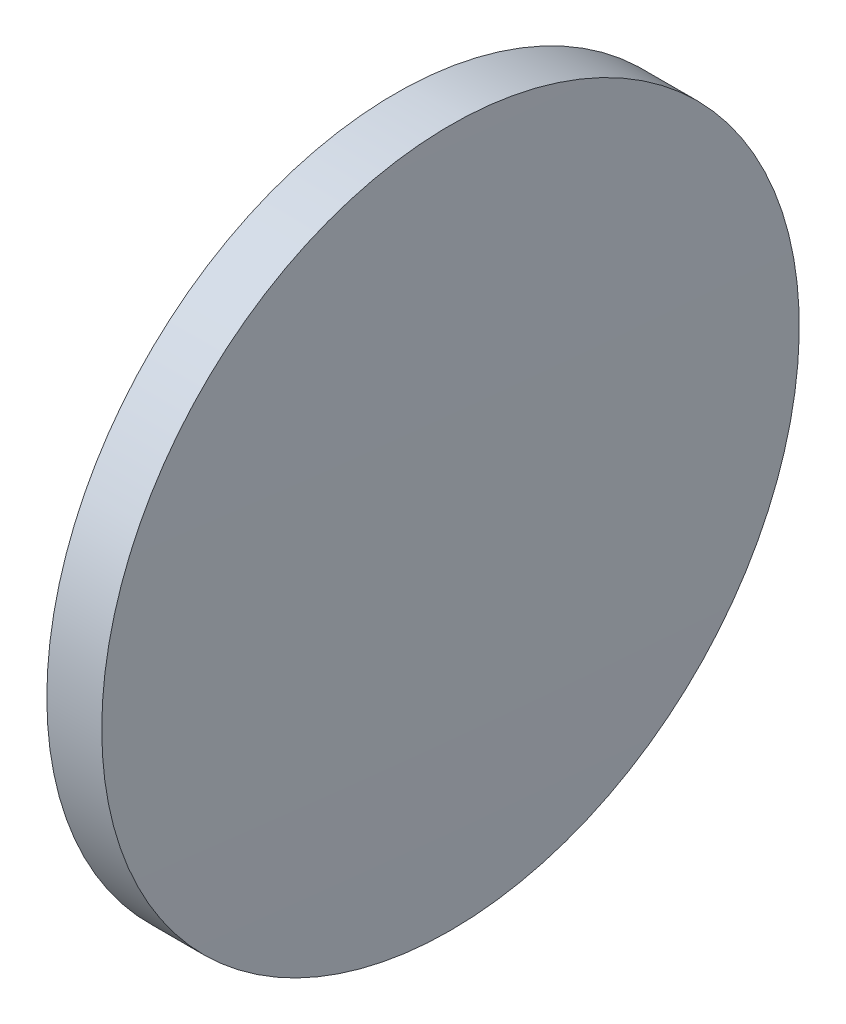
from build123d import *


with BuildPart() as part:
    # 草图1 → 旋转1 (revolve)
    with BuildSketch(Plane.XY, mode=Mode.PRIVATE) as revolve_1_sk:
        with BuildLine():
            Line((503.548443515, 171.14028798), (503.548443515, 183.84028798))
            Line((503.548443515, 183.84028798), (505.548443515, 183.84028798))
            ThreePointArc((505.548443515, 183.84028798), (505.623443127, 177.490484827), (505.648443515, 171.14028798))
            Line((505.648443515, 171.14028798), (503.548443515, 171.14028798))
        make_face()
    revolve(revolve_1_sk.sketch.rotate(Axis((497.810225479, 171.14028798, 0), (1, 0, 0)), 180), axis=Axis((497.810225479, 171.14028798, 0), (1, 0, 0)))  # turned: the seam where the file's is


solid = part.part
